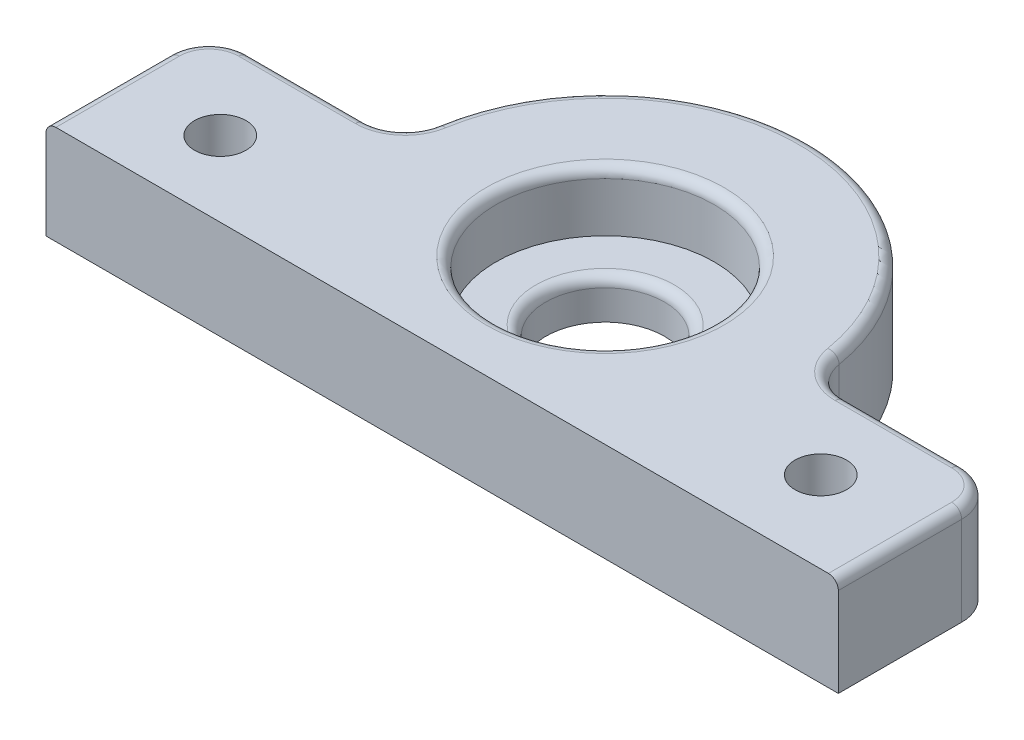
from build123d import *

# Parameters (mm, degrees)
SKETCH1_R           = 11.025
BOSS_EXTRUDE1_DEPTH = 10
SKETCH3_R           = 11.025
SKETCH3_R_2         = 6
BOSS_EXTRUDE2_DEPTH = 4
FILLET1_R           = 4
FILLET2_R           = 1
CUT_EXTRUDE1_REACH  = 12
SKETCH4_R           = 2.6


with BuildPart() as part:
    # Sketch1 → Boss-Extrude1 (new body)
    with BuildSketch(Plane(origin=(0, 0, 0), x_dir=(1, 0, 0), z_dir=(0, 1, 0))):
        with BuildLine():
            Line((-40, -16.45412), (40, -16.45412))
            Line((40, -16.45412), (40, 0))
            Line((40, 0), (20.55, 0))
            ThreePointArc((20.55, 0), (0, 20.55), (-20.55, 0))
            Line((-20.55, 0), (-40, 0))
            Line((-40, 0), (-40, -16.45412))
        make_face()
        Circle(SKETCH1_R, mode=Mode.SUBTRACT)
    extrude(amount=BOSS_EXTRUDE1_DEPTH)

    # Sketch3 → Boss-Extrude2 (add)
    with BuildSketch(Plane.XZ):
        Circle(SKETCH3_R)
        Circle(SKETCH3_R_2, mode=Mode.SUBTRACT)
    extrude(amount=-BOSS_EXTRUDE2_DEPTH)

    # Fillet1
    fillet1_edges = [part.edges().sort_by_distance(p)[0] for p in [
        (-40, 5, 0),
        (-20.55, 5, 0),
        (20.55, 5, 0),
        (40, 5, 0),
    ]]
    fillet(fillet1_edges, radius=FILLET1_R)

    # Fillet2
    fillet2_edges = [part.edges().sort_by_distance(p)[0] for p in [
        (40, 10, 10.22706),
        (-11.025, 10, 0),
        (-6, 4, 0),
        (-40, 10, 10.22706),
        (-30.110971266, 10, 0),
        (30.110971266, 10, 0),
        (0, 10, -20.55),
        (38.828427125, 10, 1.171572875),
        (-38.828427125, 10, 1.171572875),
        (-21.634175603, 10, -0.949842246),
        (21.634175603, 10, -0.949842246),
    ]]
    fillet(fillet2_edges, radius=FILLET2_R)

    # Sketch4 → Cut-Extrude1 (cut, up to next)
    with BuildSketch(Plane.XZ, mode=Mode.PRIVATE) as cut_extrude1_sk1:
        with Locations((30, 8.22706)):
            Circle(SKETCH4_R)
    cut_extrude1_tool1 = extrude(cut_extrude1_sk1.sketch, amount=-CUT_EXTRUDE1_REACH, mode=Mode.PRIVATE) & part.part
    add(cut_extrude1_tool1.solids().sort_by_distance((30, 0, 8.22706))[0], mode=Mode.SUBTRACT)
    # Sketch4 → Cut-Extrude1 (cut, up to next)
    with BuildSketch(Plane.XZ, mode=Mode.PRIVATE) as cut_extrude1_sk2:
        with Locations((-29.996640074, 8.862024441)):
            Circle(SKETCH4_R)
    cut_extrude1_tool2 = extrude(cut_extrude1_sk2.sketch, amount=-CUT_EXTRUDE1_REACH, mode=Mode.PRIVATE) & part.part
    add(cut_extrude1_tool2.solids().sort_by_distance((-29.99664, 0, 8.862024))[0], mode=Mode.SUBTRACT)


solid = part.part
